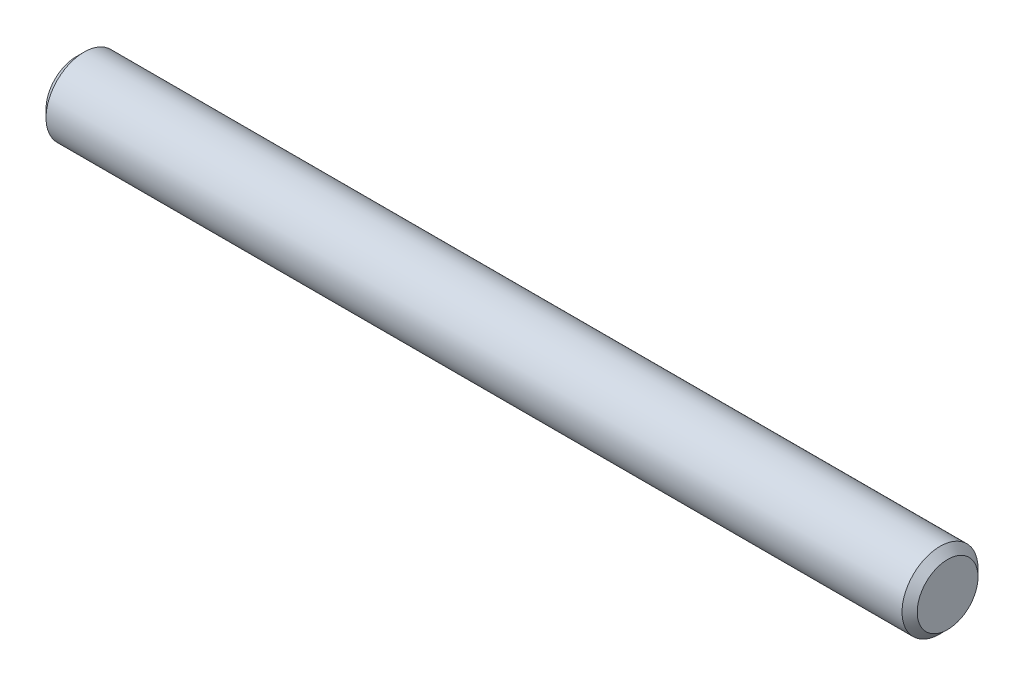
from build123d import *

# Parameters (mm, degrees)
SKETCH2_R           = 2.38125
EXTRUDE1_DEPTH      = 27.305
EXTRUDE1_DEPTH_BACK = 27.305
CHAMFER1_SIZE       = 0.47625


with BuildPart() as part:
    # Sketch2 → Extrude1 (new body, two sides)
    with BuildSketch(Plane(origin=(0, 0, 0), x_dir=(0, 0, -1), z_dir=(1, 0, 0))) as extrude1_sk:
        Circle(SKETCH2_R)
    extrude(amount=EXTRUDE1_DEPTH)
    extrude(extrude1_sk.sketch, amount=-EXTRUDE1_DEPTH_BACK)

    # Chamfer1
    chamfer1_edges = [part.edges().sort_by_distance(p)[0] for p in [
        (-27.305, 0, 2.38125),
        (27.305, 0, 2.38125),
    ]]
    chamfer(chamfer1_edges, length=CHAMFER1_SIZE)


solid = part.part
